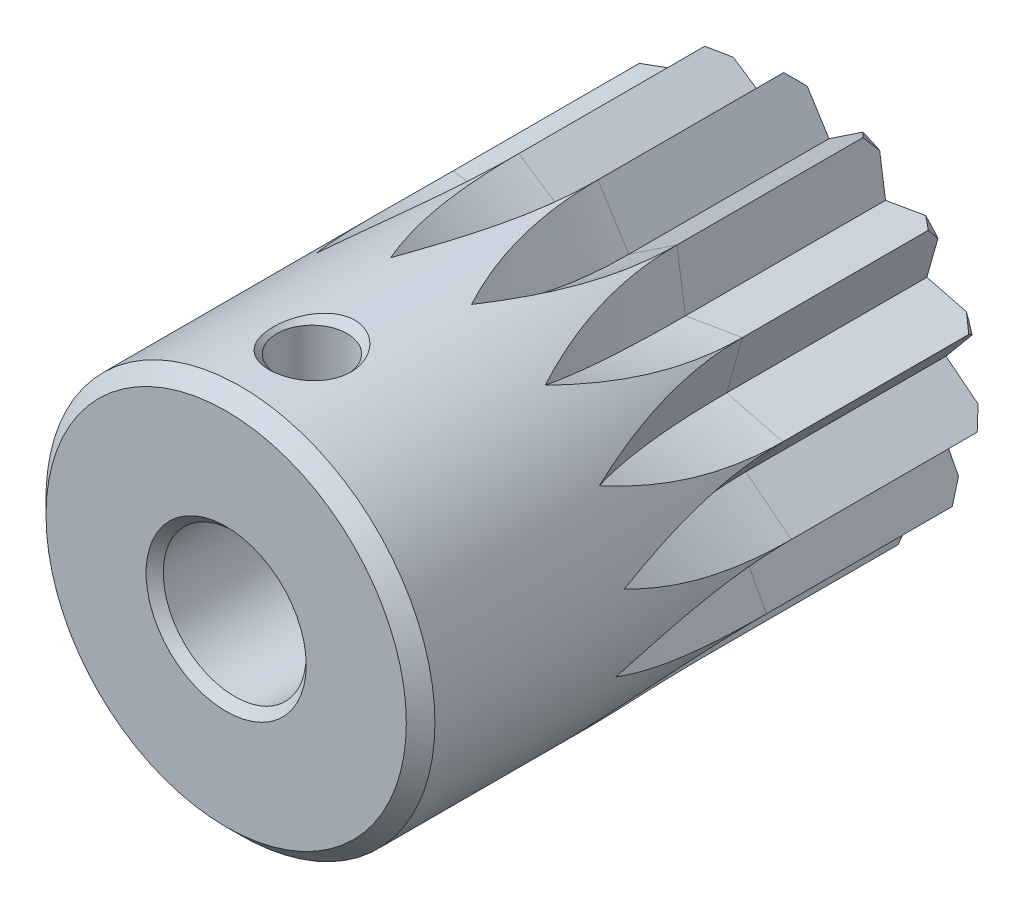
from build123d import *

# Parameters (mm, degrees)
SKETCH2_R          = 13.6
CUT_EXTRUDE1_DEPTH = 7


with BuildPart() as part:
    # Sketch1 → Revolve1 (revolve)
    with BuildSketch(Plane(origin=(0, 0, 0), x_dir=(0, 0, -1), z_dir=(1, 0, 0)), mode=Mode.PRIVATE) as revolve1_sk:
        Polygon((-20, 2.8), (-19.7, 2.5), (-0.3, 2.5), (0, 2.8), (0, 6.3), (-0.5, 6.8), (-19.5, 6.8), (-20, 6.3), align=None)
    revolve(revolve1_sk.sketch.rotate(Axis((0, 0, 0), (0, 0, 1)), 270), axis=Axis((0, 0, 0), (0, 0, 1)))

    # Sketch2 → Cut-Extrude1 (cut)
    with BuildSketch(Plane.XY.offset(7)):
        Circle(SKETCH2_R)
        Polygon((-6.762748889, -0.71079355), (-4.945493885, -1.606888371), (-5.888972746, -3.4), (-3.864353092, -3.479479153), (-3.996939716, -5.501315562), (-2.115030544, -4.75043638), (-1.413799498, -6.651403685), (0, -5.2), (1.413799498, -6.651403685), (2.115030544, -4.75043638), (3.996939716, -5.501315562), (3.864353092, -3.479479153), (5.888972746, -3.4), (4.945493885, -1.606888371), (6.762748889, -0.71079355), (5.171513856, 0.543548009), (6.467184311, 2.101315562), (4.5033321, 2.6), (5.053384813, 4.550088123), (3.056483312, 4.206888371), (2.765809173, 6.212109112), (1.081140792, 5.086367524), (0, 6.8), (-1.081140792, 5.086367524), (-2.765809173, 6.212109112), (-3.056483312, 4.206888371), (-5.053384813, 4.550088123), (-4.5033321, 2.6), (-6.467184311, 2.101315562), (-5.171513856, 0.543548009), align=None, mode=Mode.SUBTRACT)
    extrude(amount=-CUT_EXTRUDE1_DEPTH, mode=Mode.SUBTRACT)

    # Sketch3 → Cut-Revolve1 (revolve, cut)
    with BuildSketch(Plane.XY.offset(7)):
        Polygon((-2.079116908, 16.581476007), (0, 6.8), (-1.081140792, 5.086367524), (-2.765809173, 6.212109112), (-4.844926081, 15.993585119), align=None)
    revolve(axis=Axis((-4.844926081, 15.993585119, 7), (0.9781476007338276, 0.20791169081765642, 0)), mode=Mode.SUBTRACT)

    # Sketch4 → Cut-Revolve2 (revolve, cut)
    with BuildSketch(Plane.XY.offset(7)):
        Polygon((4.844926081, 15.993585119), (2.765809173, 6.212109112), (1.081140792, 5.086367524), (0, 6.8), (2.079116908, 16.581476007), align=None)
    revolve(axis=Axis((2.079116908, 16.581476007, 7), (0.9781476007337839, -0.2079116908178616, 0)), mode=Mode.SUBTRACT)

    # Sketch5 → Cut-Revolve3 (revolve, cut)
    with BuildSketch(Plane.XY.offset(7)):
        Polygon((10.931237336, 12.640258067), (5.053384813, 4.550088123), (3.056483312, 4.206888371), (2.765809173, 6.212109112), (8.643661696, 14.302279056), align=None)
    revolve(axis=Axis((8.643661696, 14.302279056, 7), (0.8090169943748879, -0.587785252292555, 0)), mode=Mode.SUBTRACT)

    # Sketch6 → Cut-Revolve4 (revolve, cut)
    with BuildSketch(Plane.XY.offset(7)):
        Polygon((15.127438349, 7.101315562), (6.467184311, 2.101315562), (4.5033321, 2.6), (5.053384813, 4.550088123), (13.713638851, 9.550088123), align=None)
    revolve(axis=Axis((13.713638851, 9.550088123, 7), (0.4999999999999118, -0.8660254037844896, 0)), mode=Mode.SUBTRACT)

    # Sketch7 → Cut-Revolve5 (revolve, cut)
    with BuildSketch(Plane.XY.offset(7)):
        Polygon((16.707967842, 0.334491082), (6.762748889, -0.71079355), (5.171513856, 0.543548009), (6.467184311, 2.101315562), (16.412403264, 3.146600194), align=None)
    revolve(axis=Axis((16.412403264, 3.146600194, 7), (0.10452846326754994, -0.9945218953682843, 0)), mode=Mode.SUBTRACT)

    # Sketch8 → Cut-Revolve6 (revolve, cut)
    with BuildSketch(Plane.XY.offset(7)):
        Polygon((15.399537909, -6.490169944), (5.888972746, -3.4), (4.945493885, -1.606888371), (6.762748889, -0.71079355), (16.273314051, -3.800963494), align=None)
    revolve(axis=Axis((16.273314051, -3.800963494, 7), (-0.3090169943750462, -0.9510565162951216, 0)), mode=Mode.SUBTRACT)

    # Sketch9 → Cut-Revolve7 (revolve, cut)
    with BuildSketch(Plane.XY.offset(7)):
        Polygon((11.42838797, -12.192621625), (3.996939716, -5.501315562), (3.864353092, -3.479479153), (5.888972746, -3.4), (13.320421001, -10.091306064), align=None)
    revolve(axis=Axis((13.320421001, -10.091306064, 7), (-0.669130606358939, -0.7431448254773216, 0)), mode=Mode.SUBTRACT)

    # Sketch10 → Cut-Revolve8 (revolve, cut)
    with BuildSketch(Plane.XY.offset(7)):
        Polygon((5.481165928, -15.786858261), (1.413799498, -6.651403685), (2.115030544, -4.75043638), (3.996939716, -5.501315562), (8.064306146, -14.636770138), align=None)
    revolve(axis=Axis((8.064306146, -14.636770138, 7), (-0.9135454576426438, -0.40673664307570384, 0)), mode=Mode.SUBTRACT)

    # Sketch11 → Cut-Revolve9 (revolve, cut)
    with BuildSketch(Plane.XY.offset(7)):
        Polygon((-1.413799498, -16.651403685), (-1.413799498, -6.651403685), (0, -5.2), (1.413799498, -6.651403685), (1.413799498, -16.651403685), align=None)
    revolve(axis=Axis((1.413799498, -16.651403685, 7), (-1, 0, 0)), mode=Mode.SUBTRACT)

    # Sketch12 → Cut-Revolve10 (revolve, cut)
    with BuildSketch(Plane.XY.offset(7)):
        Polygon((-8.064306146, -14.636770138), (-3.996939716, -5.501315562), (-2.115030544, -4.75043638), (-1.413799498, -6.651403685), (-5.481165928, -15.786858261), align=None)
    revolve(axis=Axis((-5.481165928, -15.786858261, 7), (-0.9135454576425599, 0.4067366430758923, 0)), mode=Mode.SUBTRACT)

    # Sketch13 → Cut-Revolve11 (revolve, cut)
    with BuildSketch(Plane.XY.offset(7)):
        Polygon((-13.320421001, -10.091306064), (-5.888972746, -3.4), (-3.864353092, -3.479479153), (-3.996939716, -5.501315562), (-11.42838797, -12.192621625), align=None)
    revolve(axis=Axis((-11.42838797, -12.192621625, 7), (-0.6691306063587794, 0.7431448254774652, 0)), mode=Mode.SUBTRACT)

    # Sketch14 → Cut-Revolve12 (revolve, cut)
    with BuildSketch(Plane.XY.offset(7)):
        Polygon((-16.273314051, -3.800963494), (-6.762748889, -0.71079355), (-4.945493885, -1.606888371), (-5.888972746, -3.4), (-15.399537909, -6.490169944), align=None)
    revolve(axis=Axis((-15.399537909, -6.490169944, 7), (-0.30901699437484564, 0.9510565162951867, 0)), mode=Mode.SUBTRACT)

    # Sketch15 → Cut-Revolve13 (revolve, cut)
    with BuildSketch(Plane.XY.offset(7)):
        Polygon((-16.412403264, 3.146600194), (-6.467184311, 2.101315562), (-5.171513856, 0.543548009), (-6.762748889, -0.71079355), (-16.707967842, 0.334491082), align=None)
    revolve(axis=Axis((-16.707967842, 0.334491082, 7), (0.10452846326776204, 0.994521895368262, 0)), mode=Mode.SUBTRACT)

    # Sketch16 → Cut-Revolve14 (revolve, cut)
    with BuildSketch(Plane.XY.offset(7)):
        Polygon((-13.713638851, 9.550088123), (-5.053384813, 4.550088123), (-4.5033321, 2.6), (-6.467184311, 2.101315562), (-15.127438349, 7.101315562), align=None)
    revolve(axis=Axis((-15.127438349, 7.101315562, 7), (0.5000000000000947, 0.8660254037843841, 0)), mode=Mode.SUBTRACT)

    # Sketch17 → Cut-Revolve15 (revolve, cut)
    with BuildSketch(Plane.XY.offset(7)):
        Polygon((-8.643661696, 14.302279056), (-2.765809173, 6.212109112), (-3.056483312, 4.206888371), (-5.053384813, 4.550088123), (-10.931237336, 12.640258067), align=None)
    revolve(axis=Axis((-10.931237336, 12.640258067, 7), (0.8090169943750091, 0.5877852522923883, 0)), mode=Mode.SUBTRACT)

    # Sketch18 → Cut-Revolve16 (revolve, cut)
    with BuildSketch(Plane.XY.offset(17), mode=Mode.PRIVATE) as cut_revolve16_sk:
        Polygon((0, 1.5), (-1.2295, 1.5), (-1.2295, 6.5295), (-1.5, 6.8), (-1.5, 7.8), (0, 7.8), align=None)
    revolve(cut_revolve16_sk.sketch.rotate(Axis((0, 7.8, 17), (0, -1, 0)), 45.444205102), axis=Axis((0, 7.8, 17), (0, -1, 0)), mode=Mode.SUBTRACT)


solid = part.part
